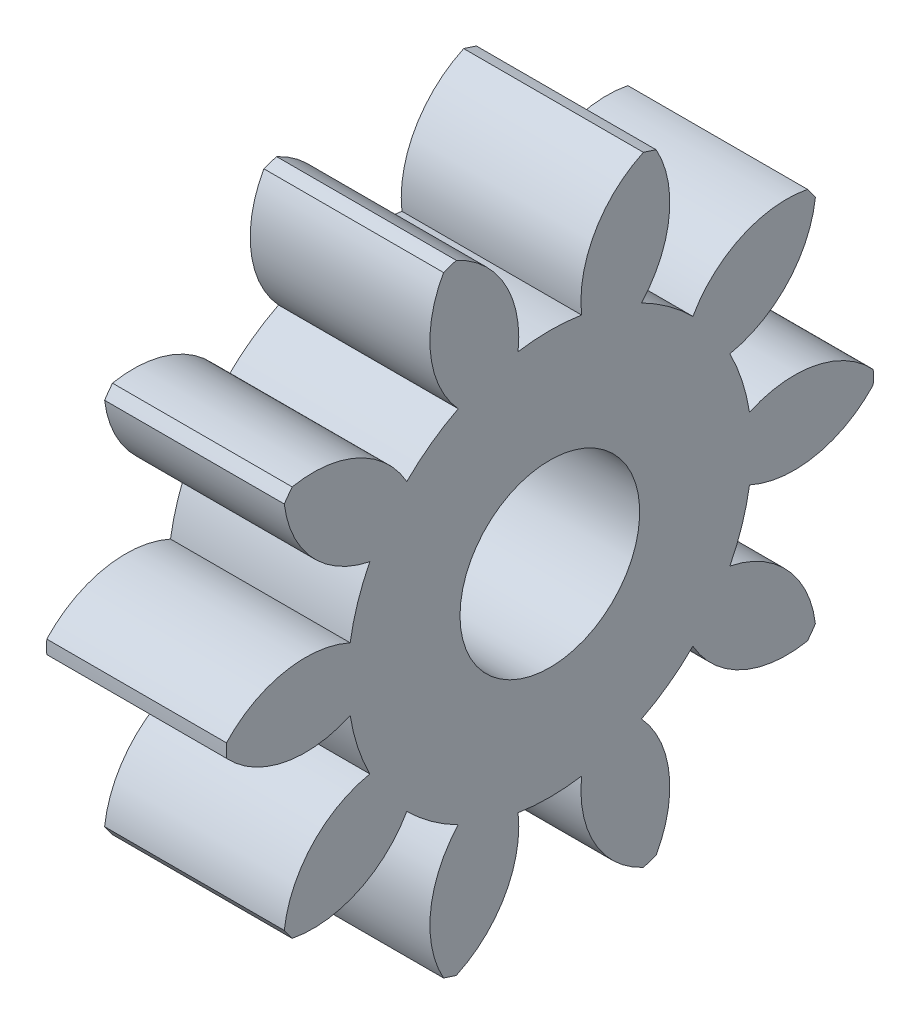
from build123d import *

# Parameters (mm, degrees)
BASPROSKE_W     = 5
BASPROSKE_H     = 9
TOOTHCUT_DEPTH  = 14.674794331
TEETHCUTS_COUNT = 10
TEETHCUTS_ANGLE = 324
BORSKE_R        = 2.5
BORE_DEPTH      = 50.0000508


with BuildPart() as part:
    # BasProSke → Base-Revolve (revolve)
    with BuildSketch(Plane(origin=(0, 0, 0), x_dir=(1, 0, 0), z_dir=(0, 1, 0)), mode=Mode.PRIVATE) as base_revolve_sk:
        with Locations((2.5, 4.5)):
            Rectangle(BASPROSKE_W, BASPROSKE_H)
    revolve(base_revolve_sk.sketch.rotate(Axis((-10, 0, 0), (1, 0, 0)), 180), axis=Axis((-10, 0, 0), (1, 0, 0)))

    # TooCutSke → ToothCut (cut, through all)
    with BuildSketch(Plane(origin=(0, 0, 0), x_dir=(0, 0, -1), z_dir=(1, 0, 0))):
        with BuildLine():
            ThreePointArc((0.883878355, 5.554109745), (0, 5.624), (-0.883878355, 5.554109745))
            ThreePointArc((-0.883878355, 5.554109745), (-1.258245767, 7.379188248), (-2.637816971, 8.631324741))
            ThreePointArc((-2.637816971, 8.631324741), (0, 9.0254), (2.637816971, 8.631324741))
            ThreePointArc((2.637816971, 8.631324741), (1.258245767, 7.379188248), (0.883878355, 5.554109745))
        make_face()
    toothcut = extrude(amount=TOOTHCUT_DEPTH, mode=Mode.SUBTRACT)

    # TeethCuts: ToothCut ×10 about axis
    teethcuts_axis = Axis((-10, 0, 0), (1, 0, 0))
    for i in range(1, TEETHCUTS_COUNT):
        add(toothcut.rotate(teethcuts_axis, i * TEETHCUTS_ANGLE / (TEETHCUTS_COUNT - 1)), mode=Mode.SUBTRACT)

    # BorSke → Bore (cut, symmetric)
    with BuildSketch(Plane(origin=(0, 0, 0), x_dir=(0, 0, -1), z_dir=(1, 0, 0))):
        with Locations(Location((0, 0, 0), (0, 0, 180))):
            Circle(BORSKE_R)
    extrude(amount=BORE_DEPTH, both=True, mode=Mode.SUBTRACT)


solid = part.part
